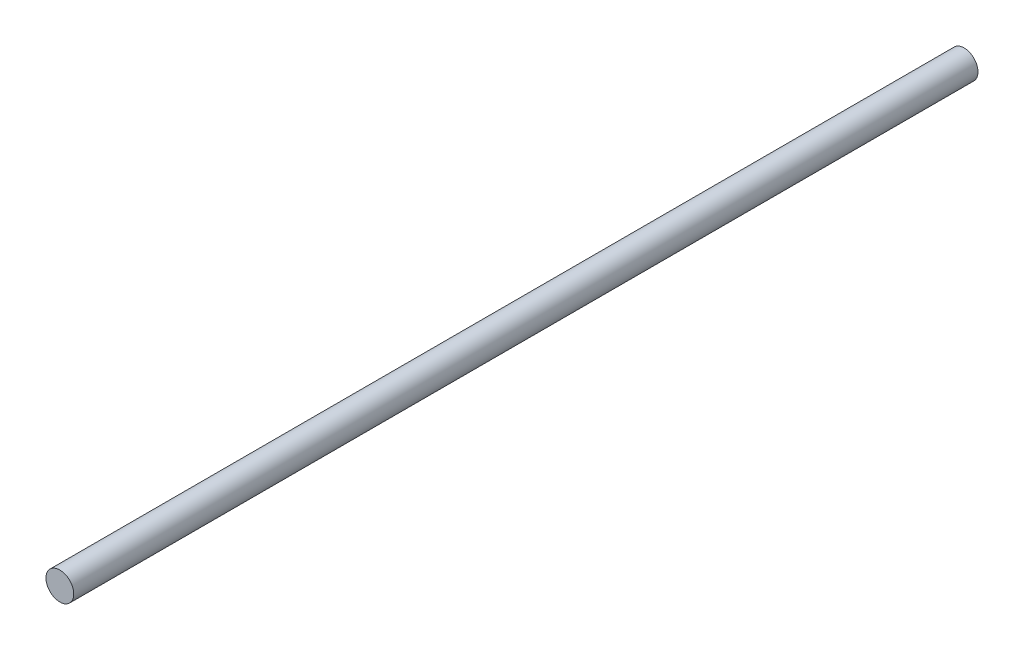
from build123d import *

# Parameters (mm, degrees)
SKETCH1_R           = 8
BOSS_EXTRUDE1_DEPTH = 521


with BuildPart() as part:
    # Sketch1 → Boss-Extrude1 (new body)
    with BuildSketch(Plane.XY):
        Circle(SKETCH1_R)
    extrude(amount=BOSS_EXTRUDE1_DEPTH)


solid = part.part
